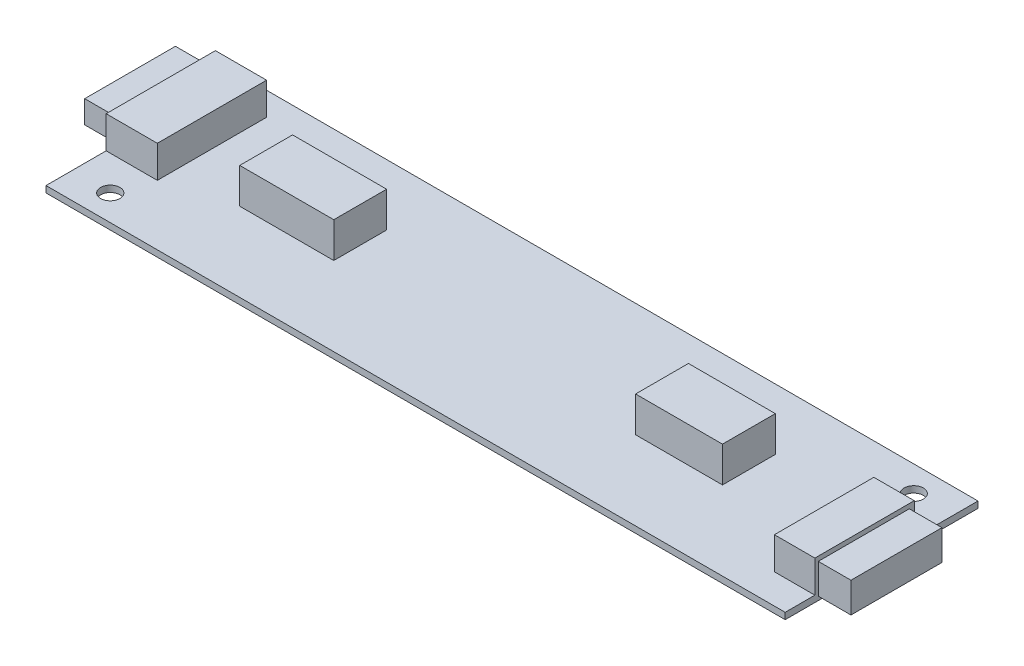
from build123d import *

# Parameters (mm, degrees)
SKETCH1_W                       = 115
SKETCH1_H                       = 30
EXTRUDE1_DEPTH                  = 1
SKETCH2_R                       = 1.5
MOUNT_HOLES_CUT_DEPTH           = 1
SKETCH4_W                       = 13.516297105
SKETCH4_H                       = 8.221252878
SKETCH4_W_2                     = 14.631043257
INDUCTORS_DEPTH                 = 5.5
SKETCH5_W                       = 6.291348601
SKETCH5_H                       = 15.467102872
SKETCH5_W_2                     = 7.96346783
SKETCH5_H_2                     = 16.999878832
CCFL_CONN_DEPTH                 = 5
SKETCH6_W                       = 14.156835531
SKETCH6_H                       = 4.690856218
MATE_AND_WIRE_STICK_OUT_1_DEPTH = 5.08
SKETCH7_W                       = 14.117118553
SKETCH7_H                       = 3.532074628
MATE_AND_WIRE_STICK_OUT_2_DEPTH = 5.08


with BuildPart() as part:
    # Sketch1 → Extrude1 (new body)
    with BuildSketch(Plane(origin=(0, 0, 0), x_dir=(1, 0, 0), z_dir=(0, 1, 0))):
        with Locations((57.5, -15)):
            Rectangle(SKETCH1_W, SKETCH1_H)
    extrude(amount=EXTRUDE1_DEPTH)

    # Sketch2 → mount holes - cut (cut)
    with BuildSketch(Plane(origin=(0, 1, 0), x_dir=(-1, 0, 0), z_dir=(0, 1, 0))):
        with Locations((-109, 4)):
            Circle(SKETCH2_R)
        with Locations((-6, 26)):
            Circle(SKETCH2_R)
    extrude(amount=-MOUNT_HOLES_CUT_DEPTH, mode=Mode.SUBTRACT)

    # Sketch4 → inductors (add)
    with BuildSketch(Plane(origin=(0, 1, 0), x_dir=(-1, 0, 0), z_dir=(0, 1, 0))):
        with Locations((-86.204713438, 13.606567309)):
            Rectangle(SKETCH4_W, SKETCH4_H)
        with Locations((-25.172361566, 13.606567309)):
            Rectangle(SKETCH4_W_2, SKETCH4_H)
    extrude(amount=INDUCTORS_DEPTH)

    # Sketch5 → ccfl conn (add)
    with BuildSketch(Plane(origin=(0, 1, 0), x_dir=(-1, 0, 0), z_dir=(0, 1, 0))):
        with Locations((-111.8543257, 17.647522113)):
            Rectangle(SKETCH5_W, SKETCH5_H)
        with Locations((-3.981733915, 12.143462983)):
            Rectangle(SKETCH5_W_2, SKETCH5_H_2)
    extrude(amount=CCFL_CONN_DEPTH)

    # Sketch6 → mate and wire stick-out 1 (add)
    with BuildSketch(Plane(origin=(115, 0, 0), x_dir=(0, 0, -1), z_dir=(1, 0, 0))):
        with Locations((-17.7667625, 2.941021447)):
            Rectangle(SKETCH6_W, SKETCH6_H)
    extrude(amount=MATE_AND_WIRE_STICK_OUT_1_DEPTH)

    # Sketch7 → mate and wire stick-out 2 (add)
    with BuildSketch(Plane.ZY):
        with Locations((11.841645931, 2.849567483)):
            Rectangle(SKETCH7_W, SKETCH7_H)
    extrude(amount=MATE_AND_WIRE_STICK_OUT_2_DEPTH)


solid = part.part
